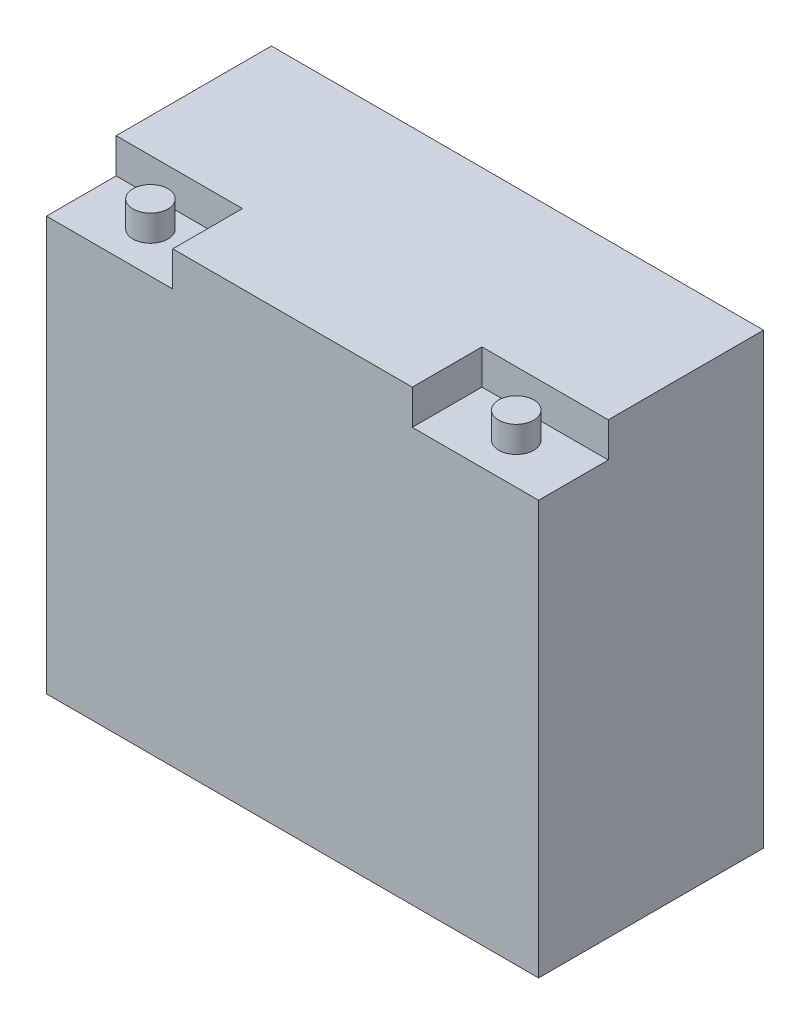
from build123d import *

# Parameters (mm, degrees)
SKETCH1_W           = 179.3875
SKETCH1_H           = 82.005714286
BOSS_EXTRUDE1_DEPTH = 163.5125
SKETCH2_W           = 46.0375
SKETCH2_H           = 25.4
CUT_EXTRUDE1_DEPTH  = 12.7
SKETCH3_R           = 6.380960286
BOSS_EXTRUDE2_DEPTH = 9.525


with BuildPart() as part:
    # Sketch1 → Boss-Extrude1 (new body)
    with BuildSketch(Plane(origin=(0, 0, 0), x_dir=(1, 0, 0), z_dir=(0, 1, 0))):
        with Locations((89.69375, 41.002857143)):
            Rectangle(SKETCH1_W, SKETCH1_H)
    extrude(amount=BOSS_EXTRUDE1_DEPTH)

    # Sketch2 → Cut-Extrude1 (cut)
    with BuildSketch(Plane(origin=(0, 163.5125, 0), x_dir=(1, 0, 0), z_dir=(0, 1, 0))):
        with Locations((23.01875, 12.7)):
            Rectangle(SKETCH2_W, SKETCH2_H)
        with Locations((156.36875, 12.7)):
            Rectangle(SKETCH2_W, SKETCH2_H)
    extrude(amount=-CUT_EXTRUDE1_DEPTH, mode=Mode.SUBTRACT)

    # Sketch3 → Boss-Extrude2 (add)
    with BuildSketch(Plane(origin=(0, 150.8125, 0), x_dir=(1, 0, 0), z_dir=(0, 1, 0))):
        with Locations((23.01875, 14.886216264)):
            Circle(SKETCH3_R)
        with Locations((156.36875, 14.886216264)):
            Circle(SKETCH3_R)
    extrude(amount=BOSS_EXTRUDE2_DEPTH)


solid = part.part
